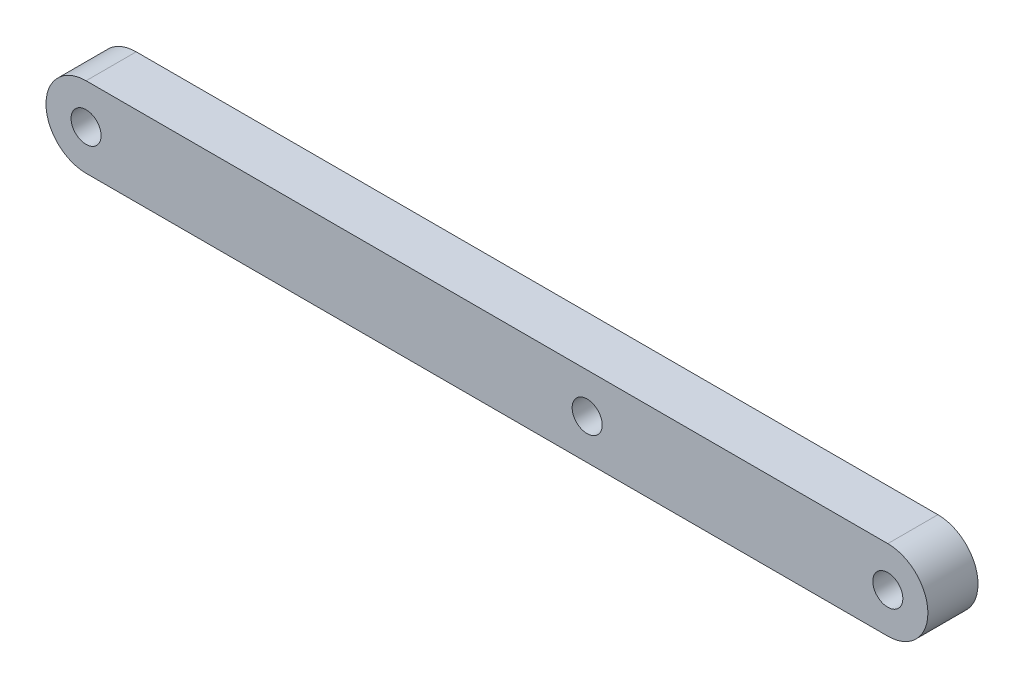
from build123d import *

# Parameters (mm, degrees)
SKETCH1_R           = 1.5
BOSS_EXTRUDE1_DEPTH = 5
SKETCH2_R           = 1.5
CUT_EXTRUDE1_DEPTH  = 10


with BuildPart() as part:
    # Sketch1 → Boss-Extrude1 (new body)
    with BuildSketch(Plane.XY):
        with BuildLine():
            Line((-97.953488372, -1), (-17.953487056, -1))
            ThreePointArc((-17.953487056, -1), (-13.953488372, -5.000000339), (-17.953487734, -9))
            Line((-17.953487734, -9), (-97.953488372, -9))
            ThreePointArc((-97.953488372, -9), (-101.953488372, -5), (-97.953488372, -1))
        make_face()
        with Locations((-97.953488372, -5)):
            Circle(SKETCH1_R, mode=Mode.SUBTRACT)
        with Locations((-17.953488372, -5)):
            Circle(SKETCH1_R, mode=Mode.SUBTRACT)
    extrude(amount=BOSS_EXTRUDE1_DEPTH)

    # Sketch2 → Cut-Extrude1 (cut)
    with BuildSketch(Plane.XY.offset(5)):
        with Locations((-47.953488372, -5)):
            Circle(SKETCH2_R)
    extrude(amount=-CUT_EXTRUDE1_DEPTH, mode=Mode.SUBTRACT)


solid = part.part
